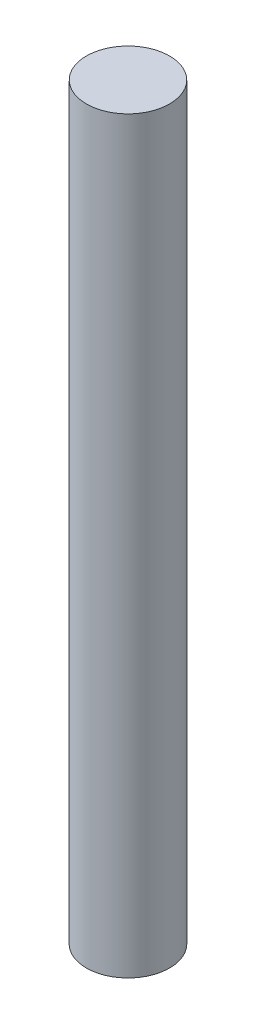
from build123d import *

# Parameters (mm, degrees)
SKETCH1_R           = 2
BOSS_EXTRUDE1_DEPTH = 18


with BuildPart() as part:
    # Sketch1 → Boss-Extrude1 (new body, symmetric)
    with BuildSketch(Plane(origin=(0, 0, 0), x_dir=(1, 0, 0), z_dir=(0, 1, 0))):
        Circle(SKETCH1_R)
    extrude(amount=BOSS_EXTRUDE1_DEPTH, both=True)


solid = part.part
